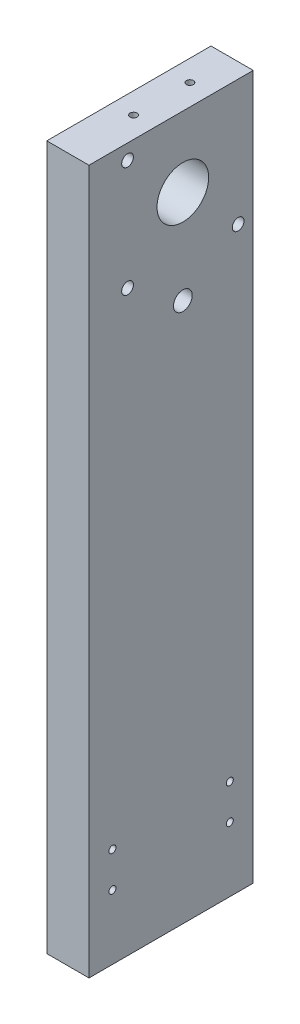
from build123d import *

# Parameters (mm, degrees)
CROQUIS2_W              = 70
CROQUIS2_H              = 300
CROQUIS2_R              = 1.5
CROQUIS2_R_2            = 4
CROQUIS2_R_3            = 2.5
CROQUIS2_R_4            = 11
SALIENTE_EXTRUIR1_DEPTH = 18
CROQUIS3_R              = 1.5
CORTAR_EXTRUIR1_DEPTH   = 14


with BuildPart() as part:
    # Croquis2 → Saliente-Extruir1 (new body)
    with BuildSketch(Plane(origin=(0, 0, 0), x_dir=(0, 0, -1), z_dir=(1, 0, 0))):
        Rectangle(CROQUIS2_W, CROQUIS2_H)
        with Locations((25, -122.5)):
            Circle(CROQUIS2_R, mode=Mode.SUBTRACT)
        with Locations((-25, -122.5)):
            Circle(CROQUIS2_R, mode=Mode.SUBTRACT)
        with Locations((25, -107.5)):
            Circle(CROQUIS2_R, mode=Mode.SUBTRACT)
        with Locations((-25, -107.5)):
            Circle(CROQUIS2_R, mode=Mode.SUBTRACT)
        with Locations((5, 80)):
            Circle(CROQUIS2_R_2, mode=Mode.SUBTRACT)
        with Locations((28.57, 96.43)):
            Circle(CROQUIS2_R_3, mode=Mode.SUBTRACT)
        with Locations((5, 120)):
            Circle(CROQUIS2_R_4, mode=Mode.SUBTRACT)
        with Locations((-18.57, 96.43)):
            Circle(CROQUIS2_R_3, mode=Mode.SUBTRACT)
        with Locations((-18.57, 143.57)):
            Circle(CROQUIS2_R_3, mode=Mode.SUBTRACT)
    extrude(amount=SALIENTE_EXTRUIR1_DEPTH)

    # Croquis3 → Cortar-Extruir1 (cut)
    with BuildSketch(Plane(origin=(0, 150, 0), x_dir=(1, 0, 0), z_dir=(0, 1, 0))):
        with Locations((9, -7)):
            Circle(CROQUIS3_R)
        with Locations((9, 17)):
            Circle(CROQUIS3_R)
    extrude(amount=-CORTAR_EXTRUIR1_DEPTH, mode=Mode.SUBTRACT)


solid = part.part
